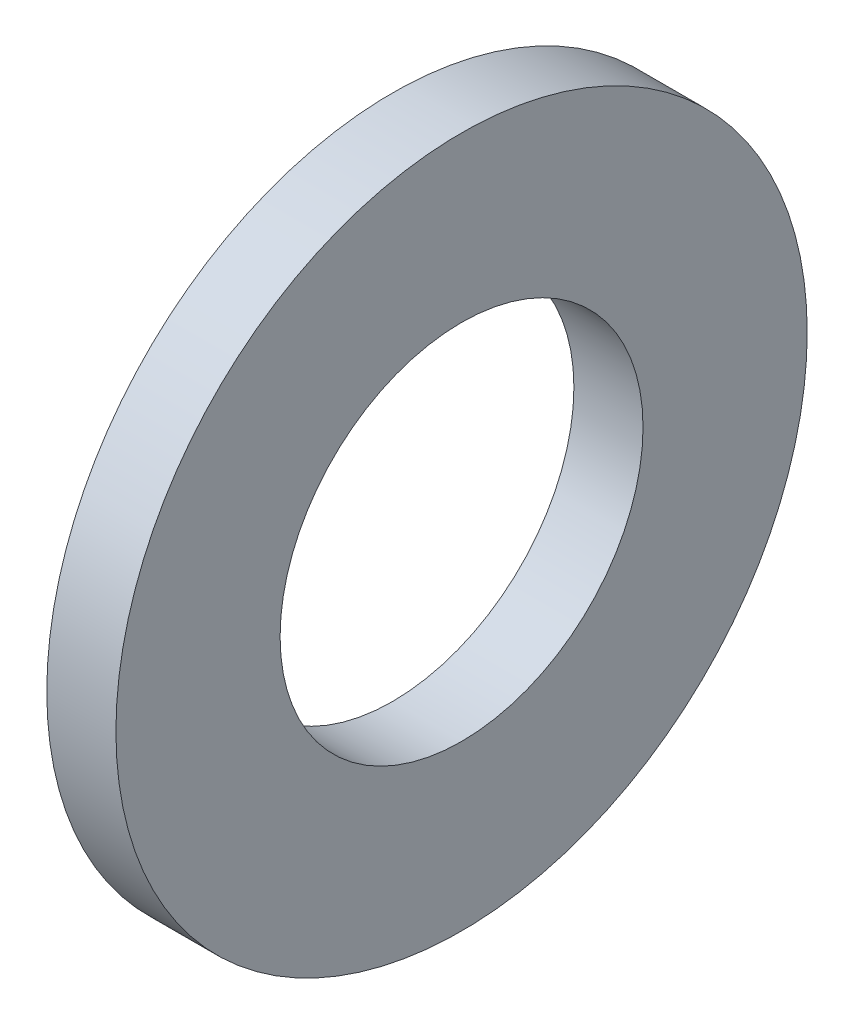
from build123d import *

# Parameters (mm, degrees)
SKETCH1_W = 1.6
SKETCH1_H = 3.8


with BuildPart() as part:
    # Sketch1 → Base-Revolve (revolve)
    with BuildSketch(Plane.XY):
        with Locations((-0.8, 6.1)):
            Rectangle(SKETCH1_W, SKETCH1_H)
    revolve(axis=Axis((-34.925, 0, 0), (1, 0, 0)))


solid = part.part
